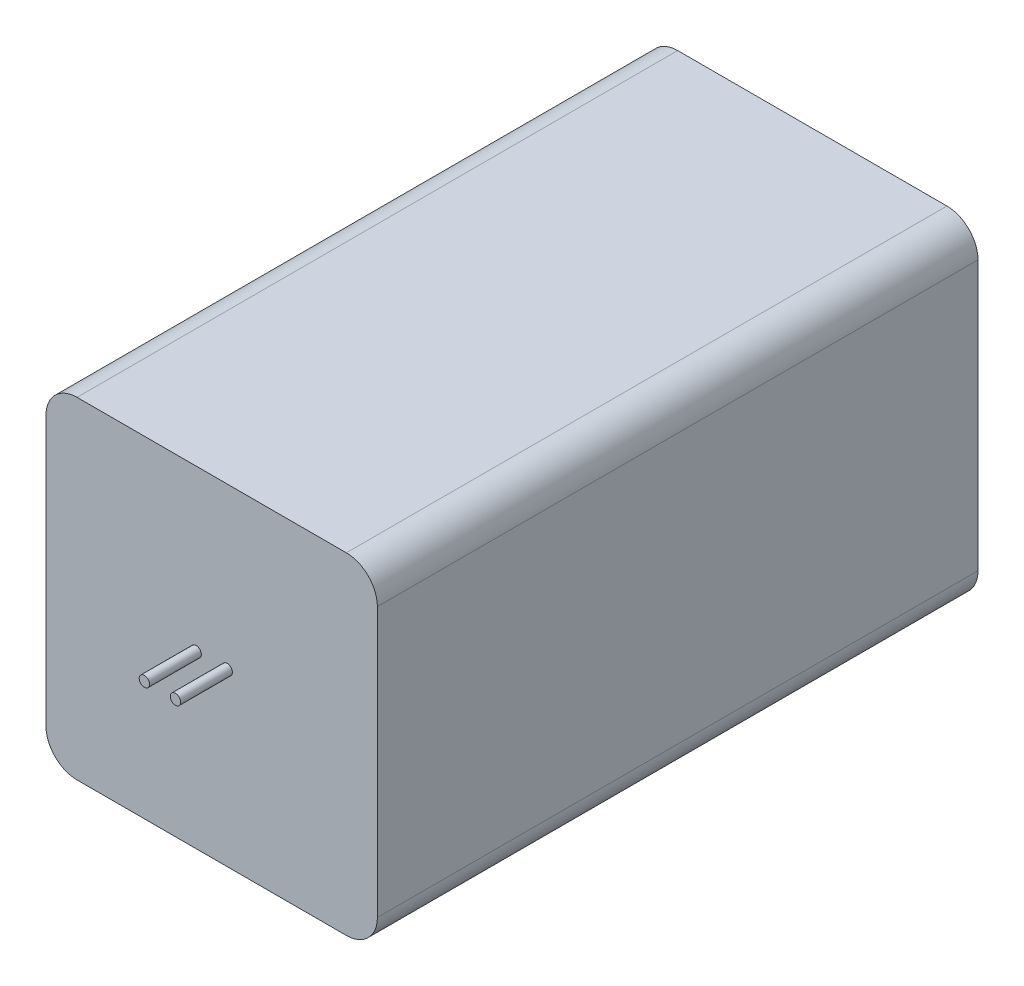
from build123d import *

# Parameters (mm, degrees)
SKETCH_1_W        = 32
SKETCH_1_H        = 32
EXTRUDE_1_DEPTH   = 58
FILLET_1_R        = 3
SKETCH_2_R        = 0.5
EXTRUDE_2_DEPTH   = 5
EXTRUDE_2_2_DEPTH = 5


with BuildPart() as part:
    # ｽｹｯﾁ1 → ﾎﾞｽ - 押し出し1 (new body)
    with BuildSketch(Plane.XY):
        Rectangle(SKETCH_1_W, SKETCH_1_H)
    extrude(amount=EXTRUDE_1_DEPTH)

    # ﾌｨﾚｯﾄ1
    fillet_1_edges = [part.edges().sort_by_distance(p)[0] for p in [
        (-16, 16, 29),
        (16, 16, 29),
        (16, -16, 29),
        (-16, -16, 29),
    ]]
    fillet(fillet_1_edges, radius=FILLET_1_R)


with BuildPart() as body_2:
    # ｽｹｯﾁ2 → ﾎﾞｽ - 押し出し2 (new body)
    with BuildSketch(Plane.XY.offset(58)):
        with Locations((-1.5, 0.5)):
            Circle(SKETCH_2_R)
    extrude(amount=EXTRUDE_2_DEPTH)


with BuildPart() as body_3:
    # ｽｹｯﾁ2 → Extrude 2 2 (new body)
    with BuildSketch(Plane.XY.offset(58)):
        with Locations((1.5, 0.5)):
            Circle(SKETCH_2_R)
    extrude(amount=EXTRUDE_2_2_DEPTH)


solid = Compound([part.part, body_2.part, body_3.part])
